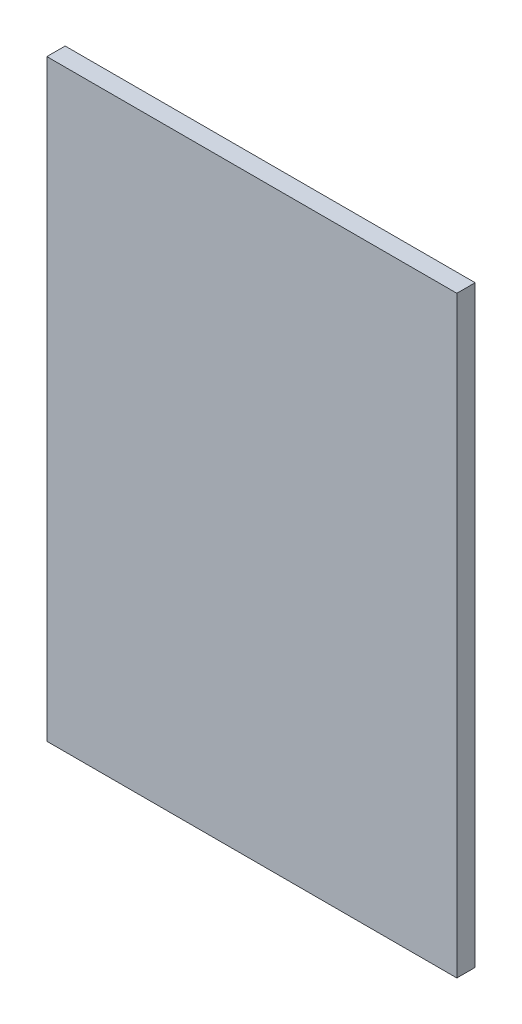
from build123d import *

# Parameters (mm, degrees)
SKETCH1_W           = 56.896
SKETCH1_H           = 82.296
BOSS_EXTRUDE1_DEPTH = 2.54


with BuildPart() as part:
    # Sketch1 → Boss-Extrude1 (new body)
    with BuildSketch(Plane.XY):
        with Locations((28.448, 41.148)):
            Rectangle(SKETCH1_W, SKETCH1_H)
    extrude(amount=BOSS_EXTRUDE1_DEPTH)


solid = part.part
